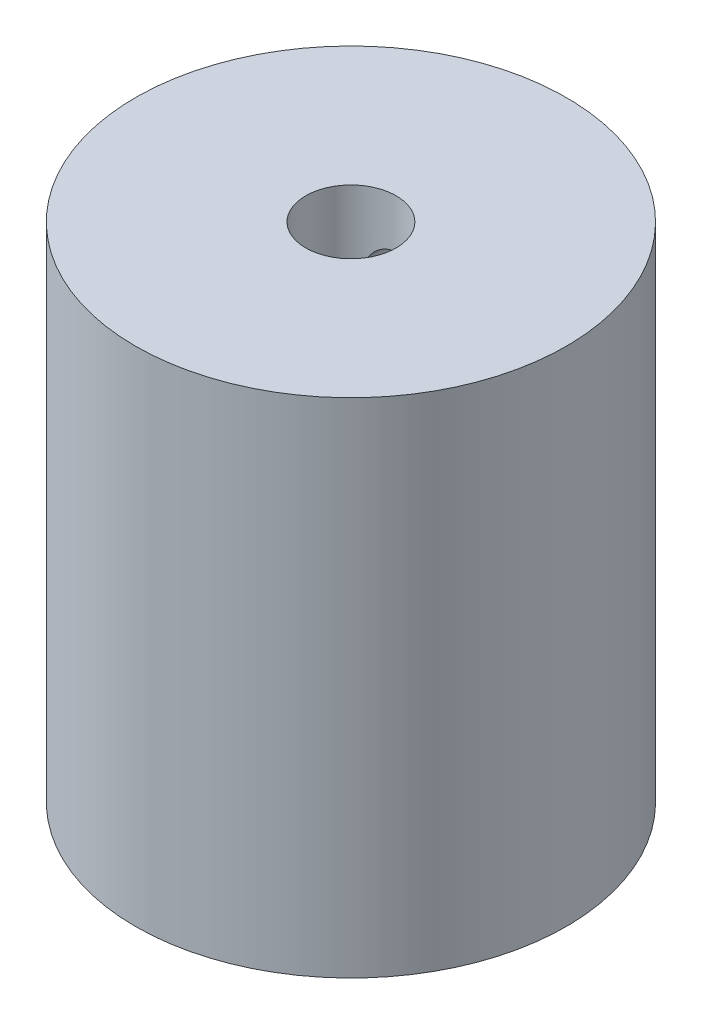
from build123d import *

# Parameters (mm, degrees)
SKETCH1_R           = 19.05
BOSS_EXTRUDE1_DEPTH = 50.8
SKETCH2_R           = 4.0000047
CUT_EXTRUDE1_DEPTH  = 25.4
SKETCH4_R           = 4
SKETCH4_R_2         = 2
CUT_EXTRUDE2_DEPTH  = 25.4
SKETCH6_R           = 2
CUT_EXTRUDE3_DEPTH  = 12.7
SKETCH7_R           = 19.05
CUT_EXTRUDE4_DEPTH  = 6.35


with BuildPart() as part:
    # Sketch1 → Boss-Extrude1 (new body)
    with BuildSketch(Plane(origin=(0, 0, 0), x_dir=(1, 0, 0), z_dir=(0, 1, 0))):
        Circle(SKETCH1_R)
    extrude(amount=BOSS_EXTRUDE1_DEPTH)

    # Sketch2 → Cut-Extrude1 (cut)
    with BuildSketch(Plane(origin=(0, 50.8, 0), x_dir=(1, 0, 0), z_dir=(0, 1, 0))):
        Circle(SKETCH2_R)
    extrude(amount=-CUT_EXTRUDE1_DEPTH, mode=Mode.SUBTRACT)

    # Sketch4 → Cut-Extrude2 (cut)
    with BuildSketch(Plane(origin=(0, 0, -19.05), x_dir=(-1, 0, 0), z_dir=(0, 0, -1))):
        with Locations((0, 12.7)):
            Circle(SKETCH4_R)
        with Locations((0.188503161, 38.1)):
            Circle(SKETCH4_R_2)
    extrude(amount=-CUT_EXTRUDE2_DEPTH, mode=Mode.SUBTRACT)

    # Sketch6 → Cut-Extrude3 (cut)
    with BuildSketch(Plane.XZ):
        Circle(SKETCH6_R)
    extrude(amount=-CUT_EXTRUDE3_DEPTH, mode=Mode.SUBTRACT)

    # Sketch7 → Cut-Extrude4 (cut)
    with BuildSketch(Plane(origin=(0, 50.8, 0), x_dir=(1, 0, 0), z_dir=(0, 1, 0))):
        Circle(SKETCH7_R)
    extrude(amount=-CUT_EXTRUDE4_DEPTH, mode=Mode.SUBTRACT)


solid = part.part
